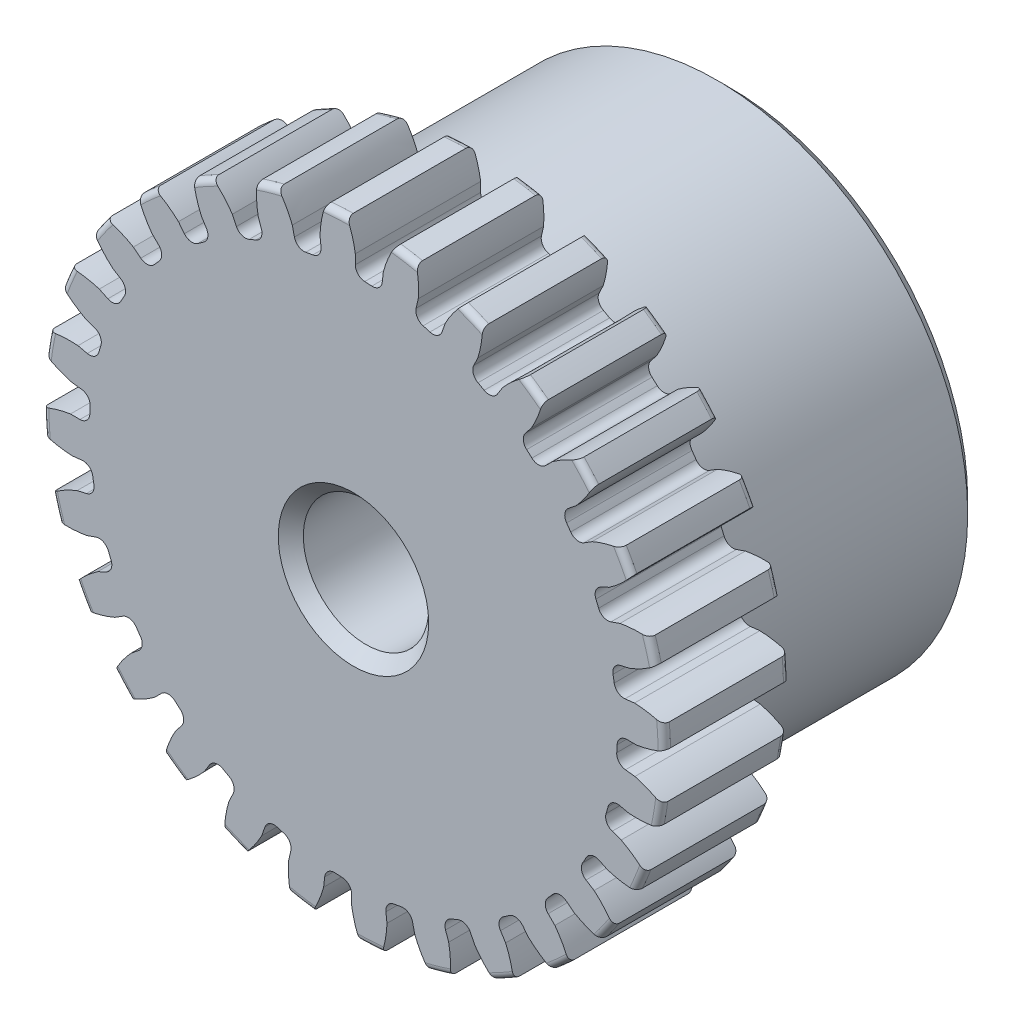
from build123d import *

# Parameters (mm, degrees)
SKETCH1_R                = 7.874
BOSS_EXTRUDE1_DEPTH      = 3.175
SKETCH2_W                = 6.35
SKETCH2_H                = 6.35
REVOLVE1_ANGLE           = 360
FILLET2_R                = 0.15748
CUT_EXTRUDE1_DEPTH       = 10.525
FILLET1_R                = 0.249222006
CIRPATTERN1_COUNT        = 28
FILLET1_OF_CIRPATTERN1_R = 0.249222006
SKETCH5_R                = 1.5875
CUT_EXTRUDE2_DEPTH       = 10.525
CHAMFER1_SIZE            = 0.3175


with BuildPart() as part:
    # Sketch1 → Boss-Extrude1 (new body)
    with BuildSketch(Plane.XY):
        Circle(SKETCH1_R)
    extrude(amount=-BOSS_EXTRUDE1_DEPTH)

    # Sketch2 → Revolve1 (revolve, symmetric)
    with BuildSketch(Plane(origin=(0, 0, 0), x_dir=(0, 0, -1), z_dir=(1, 0, 0))) as revolve1_sk:
        with Locations((6.35, 3.175)):
            Rectangle(SKETCH2_W, SKETCH2_H)
    revolve(axis=Axis((0, 0, -3.175), (0, 0, -1)), revolution_arc=REVOLVE1_ANGLE / 2)
    revolve(revolve1_sk.sketch, axis=Axis((0, 0, -3.175), (0, 0, 1)), revolution_arc=REVOLVE1_ANGLE / 2)

    # Fillet2
    fillet2_edges = [part.edges().sort_by_distance(p)[0] for p in [
        (-7.874, 0, 0),
        (-7.874, 0, -3.175),
        (0, -6.35, -3.175),
    ]]
    fillet(fillet2_edges, radius=FILLET2_R)

    # Sketch4 → Cut-Extrude1 (cut, through all)
    with BuildSketch(Plane.XY):
        with BuildLine():
            Line((0.046407635, 7.16811172), (0.046407635, 6.68389425))
            ThreePointArc((0.046407635, 6.68389425), (0.374778849, 6.673540052), (0.702244628, 6.647063148))
            Line((0.702244628, 6.647063148), (0.75645991, 7.128235946))
            add(Edge.make_bspline(
                [(1.714771634, 8.558246366), (0.980352344, 7.965902347), (0.75645991, 7.128235946)],
                knots=[0, 0, 0, 1, 1, 1], degree=2))
            ThreePointArc((1.714771634, 8.558246366), (0.489403403, 8.714614559), (-0.745767657, 8.696427612))
            add(Edge.make_bspline(
                [(-0.745767657, 8.696427612), (-0.082287906, 8.025579083), (0.046407635, 7.16811172)],
                knots=[0, 0, 0, 1, 1, 1], degree=2))
        make_face()
    cut_extrude1 = extrude(amount=-CUT_EXTRUDE1_DEPTH, mode=Mode.SUBTRACT)

    # Fillet1
    fillet1_edges = [part.edges().sort_by_distance(p)[0] for p in [
        (0.702244628, 6.647063148, -1.5875),
        (0.046407635, 6.68389425, -1.5875),
    ]]
    fillet(fillet1_edges, radius=FILLET1_R)

    # CirPattern1: Cut-Extrude1 ×28 about axis
    cirpattern1_axis = Axis((0, 0, -3.175), (0, 0, 1))
    for i in range(1, CIRPATTERN1_COUNT):
        add(cut_extrude1.rotate(cirpattern1_axis, i * 360 / CIRPATTERN1_COUNT), mode=Mode.SUBTRACT)

    # Fillet1 of CirPattern1
    fillet1_of_cirpattern1_edges = [part.edges().sort_by_distance(p)[0] for p in [
        (-0.794472811, 6.636671528, -1.5875),
        (-1.442062292, 6.526641737, -1.5875),
        (-2.251352065, 6.293489485, -1.5875),
        (-2.858221195, 6.042116154, -1.5875),
        (-3.595339127, 5.6347256, -1.5875),
        (-4.131056951, 5.254613638, -1.5875),
        (-4.759040871, 4.693413044, -1.5875),
        (-5.196744263, 4.203622852, -1.5875),
        (-5.684104435, 3.516753161, -1.5875),
        (-6.001845118, 2.941844864, -1.5875),
        (-6.324143267, 2.163748589, -1.5875),
        (-6.505988396, 1.53255049, -1.5875),
        (-6.647063148, 0.702244628, -1.5875),
        (-6.68389425, 0.046407635, -1.5875),
        (-6.636671528, -0.794472811, -1.5875),
        (-6.526641737, -1.442062292, -1.5875),
        (-6.293489485, -2.251352065, -1.5875),
        (-6.042116154, -2.858221195, -1.5875),
        (-5.6347256, -3.595339127, -1.5875),
        (-5.254613638, -4.131056951, -1.5875),
        (-4.693413044, -4.759040871, -1.5875),
        (-4.203622852, -5.196744263, -1.5875),
        (-3.516753161, -5.684104435, -1.5875),
        (-2.941844864, -6.001845118, -1.5875),
        (-2.163748589, -6.324143267, -1.5875),
        (-1.53255049, -6.505988396, -1.5875),
        (-0.702244628, -6.647063148, -1.5875),
        (-0.046407635, -6.68389425, -1.5875),
        (0.794472811, -6.636671528, -1.5875),
        (1.442062292, -6.526641737, -1.5875),
        (2.251352065, -6.293489485, -1.5875),
        (2.858221195, -6.042116154, -1.5875),
        (3.595339127, -5.6347256, -1.5875),
        (4.131056951, -5.254613638, -1.5875),
        (4.759040871, -4.693413044, -1.5875),
        (5.196744263, -4.203622852, -1.5875),
        (5.684104435, -3.516753161, -1.5875),
        (6.001845118, -2.941844864, -1.5875),
        (6.324143267, -2.163748589, -1.5875),
        (6.505988396, -1.53255049, -1.5875),
        (6.647063148, -0.702244628, -1.5875),
        (6.68389425, -0.046407635, -1.5875),
        (6.636671528, 0.794472811, -1.5875),
        (6.526641737, 1.442062292, -1.5875),
        (6.293489485, 2.251352065, -1.5875),
        (6.042116154, 2.858221195, -1.5875),
        (5.6347256, 3.595339127, -1.5875),
        (5.254613638, 4.131056951, -1.5875),
        (4.693413044, 4.759040871, -1.5875),
        (4.203622852, 5.196744263, -1.5875),
        (3.516753161, 5.684104435, -1.5875),
        (2.941844864, 6.001845118, -1.5875),
        (2.163748589, 6.324143267, -1.5875),
        (1.53255049, 6.505988396, -1.5875),
    ]]
    fillet(fillet1_of_cirpattern1_edges, radius=FILLET1_OF_CIRPATTERN1_R)

    # Sketch5 → Cut-Extrude2 (cut, through all)
    with BuildSketch(Plane.XY):
        Circle(SKETCH5_R)
    extrude(amount=-CUT_EXTRUDE2_DEPTH, mode=Mode.SUBTRACT)

    # Chamfer1
    chamfer1_edges = [part.edges().sort_by_distance(p)[0] for p in [
        (0, -6.35, -9.525),
        (-1.5875, 0, -9.525),
        (-1.5875, 0, 0),
    ]]
    chamfer(chamfer1_edges, length=CHAMFER1_SIZE)


solid = part.part
